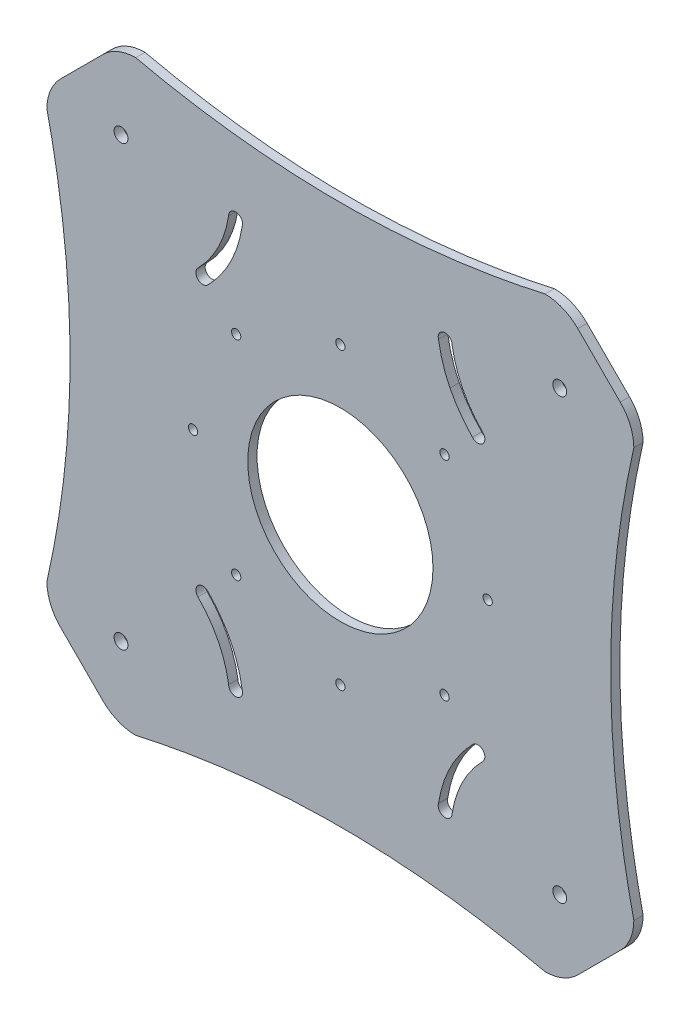
from build123d import *

# Parameters (mm, degrees)
SKETCH1_R           = 1.5
SKETCH1_R_2         = 1
SKETCH1_R_3         = 20
BOSS_EXTRUDE1_DEPTH = 2


with BuildPart() as part:
    # Sketch1 → Boss-Extrude1 (new body)
    with BuildSketch(Plane.XY):
        with BuildLine():
            Line((60.447222151, 51.275649276), (51.275649276, 60.447222151))
            ThreePointArc((51.275649276, 60.447222151), (48.031415788, 62.614949665), (44.204581464, 63.376154339))
            add(Edge.make_bspline(
                [(-44.204581464, 63.376154339), (0, 53.376154339), (44.204581464, 63.376154339)],
                knots=[0, 0, 0, 1, 1, 1], degree=2))
            ThreePointArc((-44.204581464, 63.376154339), (-48.031415788, 62.614949665), (-51.275649276, 60.447222151))
            Line((-51.275649276, 60.447222151), (-60.447222151, 51.275649276))
            ThreePointArc((-60.447222151, 51.275649276), (-62.614949665, 48.031415788), (-63.376154339, 44.204581464))
            add(Edge.make_bspline(
                [(-63.376154339, -44.204581464), (-53.376154339, 0), (-63.376154339, 44.204581464)],
                knots=[0, 0, 0, 1, 1, 1], degree=2))
            ThreePointArc((-63.376154339, -44.204581464), (-62.614949665, -48.031415788), (-60.447222151, -51.275649276))
            Line((-60.447222151, -51.275649276), (-51.275649276, -60.447222151))
            ThreePointArc((-51.275649276, -60.447222151), (-48.031415788, -62.614949665), (-44.204581464, -63.376154339))
            add(Edge.make_bspline(
                [(44.204581464, -63.376154339), (0, -53.376154339), (-44.204581464, -63.376154339)],
                knots=[0, 0, 0, 1, 1, 1], degree=2))
            ThreePointArc((44.204581464, -63.376154339), (48.031415788, -62.614949665), (51.275649276, -60.447222151))
            Line((51.275649276, -60.447222151), (60.447222151, -51.275649276))
            ThreePointArc((60.447222151, -51.275649276), (62.614949665, -48.031415788), (63.376154339, -44.204581464))
            add(Edge.make_bspline(
                [(63.376154339, 44.204581464), (53.376154339, 0), (63.376154339, -44.204581464)],
                knots=[0, 0, 0, 1, 1, 1], degree=2))
            ThreePointArc((63.376154339, 44.204581464), (62.614949665, 48.031415788), (60.447222151, 51.275649276))
        make_face()
        with Locations((-47.376154339, -47.376154339)):
            Circle(SKETCH1_R, mode=Mode.SUBTRACT)
        with BuildLine():
            ThreePointArc((-28.761031711, -28.527510136), (-28.631586297, -28.644099888), (-28.51653182, -28.774911786))
            add(Edge.make_bspline(
                [(-21.191797917, -43.405881611), (-22.512426592, -34.921752495), (-28.516531822, -28.774911788)],
                knots=[0.024414386, 0.024414386, 0.024414386, 0.9806816, 0.9806816, 0.9806816], degree=2))
            ThreePointArc((-21.191797914, -43.40588161), (-21.143599518, -43.62088039), (-21.127416998, -43.840620434))
            ThreePointArc((-21.127416998, -43.840620434), (-22.627416998, -45.340620434), (-24.127416998, -43.840620434))
            add(Edge.make_bspline(
                [(-24.127416998, -43.840620434), (-25.362407372, -36.251653189), (-30.759144982, -30.759144982)],
                knots=[0, 0, 0, 1, 1, 1], degree=2))
            ThreePointArc((-30.759144982, -30.759144982), (-30.816001484, -28.697906735), (-28.761031711, -28.527510136))
        make_face(mode=Mode.SUBTRACT)
        with Locations((-31.8198, 0)):
            Circle(SKETCH1_R_2, mode=Mode.SUBTRACT)
        with Locations((-22.499996356, -22.499996356)):
            Circle(SKETCH1_R_2, mode=Mode.SUBTRACT)
        with Locations((0, -31.8198)):
            Circle(SKETCH1_R_2, mode=Mode.SUBTRACT)
        with BuildLine():
            add(Edge.make_bspline(
                [(24.127416998, -43.840620434), (25.362407372, -36.251653189), (30.759144982, -30.759144982)],
                knots=[0, 0, 0, 1, 1, 1], degree=2))
            ThreePointArc((24.127416998, -43.840620434), (22.627416998, -45.340620434), (21.127416998, -43.840620434))
            ThreePointArc((21.127416998, -43.840620434), (21.143599518, -43.62088039), (21.191797914, -43.40588161))
            add(Edge.make_bspline(
                [(21.191797917, -43.405881611), (22.512426592, -34.921752495), (28.516531822, -28.774911788)],
                knots=[0.024414386, 0.024414386, 0.024414386, 0.9806816, 0.9806816, 0.9806816], degree=2))
            ThreePointArc((28.51653182, -28.774911786), (28.631586297, -28.644099888), (28.761031711, -28.527510136))
            ThreePointArc((28.761031711, -28.527510136), (30.816001484, -28.697906735), (30.759144982, -30.759144982))
        make_face(mode=Mode.SUBTRACT)
        with Locations((47.376154339, -47.376154339)):
            Circle(SKETCH1_R, mode=Mode.SUBTRACT)
        with Locations((22.499996356, -22.499996356)):
            Circle(SKETCH1_R_2, mode=Mode.SUBTRACT)
        Circle(SKETCH1_R_3, mode=Mode.SUBTRACT)
        with Locations((31.8198, 0)):
            Circle(SKETCH1_R_2, mode=Mode.SUBTRACT)
        with Locations((-22.499996356, 22.499996356)):
            Circle(SKETCH1_R_2, mode=Mode.SUBTRACT)
        with Locations((-47.376154339, 47.376154339)):
            Circle(SKETCH1_R, mode=Mode.SUBTRACT)
        with BuildLine():
            add(Edge.make_bspline(
                [(-24.127416998, 43.840620434), (-25.362407372, 36.251653189), (-30.759144982, 30.759144982)],
                knots=[0, 0, 0, 1, 1, 1], degree=2))
            ThreePointArc((-24.127416998, 43.840620434), (-22.627416998, 45.340620434), (-21.127416998, 43.840620434))
            ThreePointArc((-21.127416998, 43.840620434), (-21.143599518, 43.62088039), (-21.191797914, 43.40588161))
            add(Edge.make_bspline(
                [(-21.191797917, 43.405881611), (-22.512426592, 34.921752495), (-28.516531822, 28.774911788)],
                knots=[0.024414386, 0.024414386, 0.024414386, 0.9806816, 0.9806816, 0.9806816], degree=2))
            ThreePointArc((-28.51653182, 28.774911786), (-28.631586297, 28.644099888), (-28.761031711, 28.527510136))
            ThreePointArc((-28.761031711, 28.527510136), (-30.816001484, 28.697906735), (-30.759144982, 30.759144982))
        make_face(mode=Mode.SUBTRACT)
        with Locations((22.499996356, 22.499996356)):
            Circle(SKETCH1_R_2, mode=Mode.SUBTRACT)
        with Locations((0, 31.8198)):
            Circle(SKETCH1_R_2, mode=Mode.SUBTRACT)
        with BuildLine():
            ThreePointArc((28.761031711, 28.527510136), (28.631586297, 28.644099888), (28.51653182, 28.774911786))
            add(Edge.make_bspline(
                [(23.673604803, 35.525452482), (25.506528794, 31.856471559), (28.516531822, 28.774911788)],
                knots=[0.501281739, 0.501281739, 0.501281739, 0.9806816, 0.9806816, 0.9806816], degree=2))
            add(Edge.make_bspline(
                [(21.191797917, 43.405881611), (21.850363527, 39.175051421), (23.673604803, 35.525452482)],
                knots=[0.024414386, 0.024414386, 0.024414386, 0.501281739, 0.501281739, 0.501281739], degree=2))
            ThreePointArc((21.191797914, 43.40588161), (21.143599518, 43.62088039), (21.127416998, 43.840620434))
            ThreePointArc((21.127416998, 43.840620434), (22.627416998, 45.340620434), (24.127416998, 43.840620434))
            add(Edge.make_bspline(
                [(24.127416998, 43.840620434), (24.734971072, 40.107224563), (26.349731434, 36.881203745)],
                knots=[0, 0, 0, 0.491950453, 0.491950453, 0.491950453], degree=2))
            ThreePointArc((26.349731434, 36.881203745), (26.356395509, 36.86807251), (26.362930356, 36.854876488))
            add(Edge.make_bspline(
                [(26.362930356, 36.854876488), (28.028171669, 33.538582193), (30.759144982, 30.759144982)],
                knots=[0.493958478, 0.493958478, 0.493958478, 1, 1, 1], degree=2))
            ThreePointArc((30.759144982, 30.759144982), (30.816001484, 28.697906735), (28.761031711, 28.527510136))
        make_face(mode=Mode.SUBTRACT)
        with Locations((47.376154339, 47.376154339)):
            Circle(SKETCH1_R, mode=Mode.SUBTRACT)
    extrude(amount=BOSS_EXTRUDE1_DEPTH)


solid = part.part
